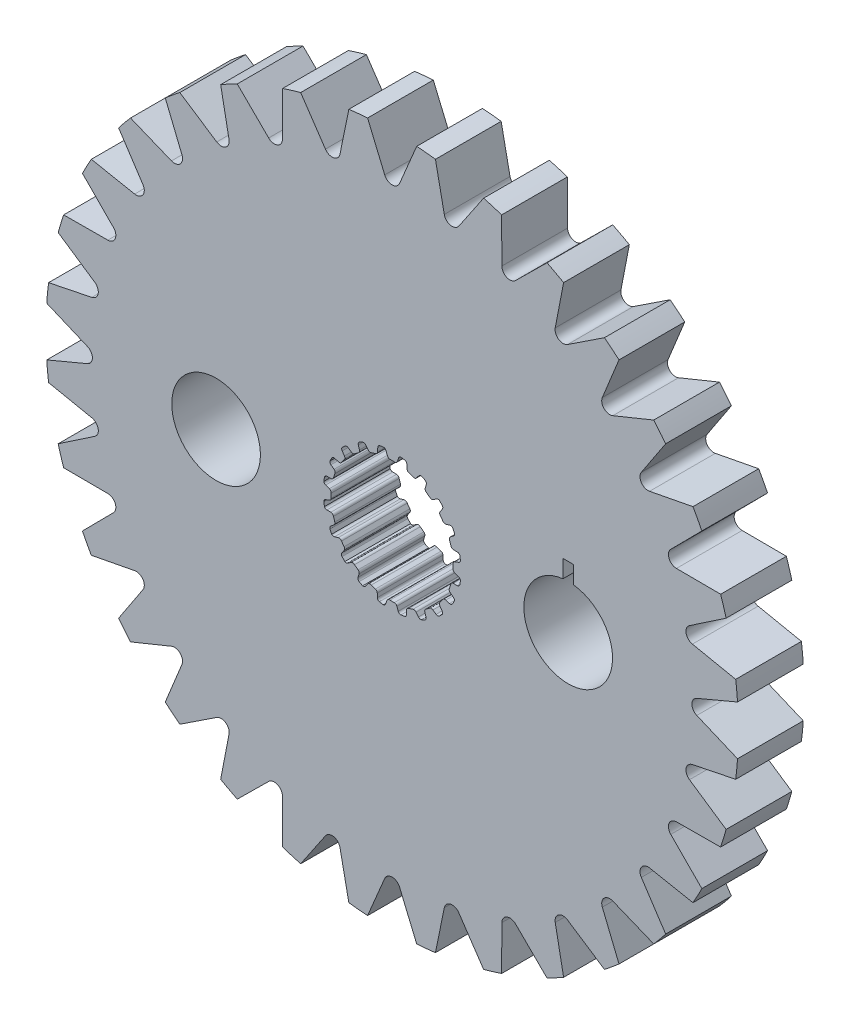
from build123d import *

# Parameters (mm, degrees)
SKETCH1_R           = 16.860601328
BOSS_EXTRUDE1_DEPTH = 1.6002
CUT_EXTRUDE1_DEPTH  = 3.2004
SKETCH4_R           = 2.159
CUT_EXTRUDE2_DEPTH  = 3.2004
SKETCH5_W           = 0.508
SKETCH5_H           = 1.27
CUT_EXTRUDE3_DEPTH  = 3.2004


with BuildPart() as part:
    # Sketch1 → Boss-Extrude1 (new body, symmetric)
    with BuildSketch(Plane.XY):
        Circle(SKETCH1_R)
        with BuildLine():
            Line((-0.106949245, 2.969874934), (0.106949245, 2.969874934))
            ThreePointArc((0.106949245, 2.969874934), (0.196343213, 2.986924176), (0.253739238, 3.057547504))
            Line((0.253739238, 3.057547504), (0.315888147, 3.237526941))
            ThreePointArc((0.315888147, 3.237526941), (0.359032156, 3.298322911), (0.4281449, 3.326269005))
            Line((0.4281449, 3.326269005), (0.620027588, 3.2937547))
            ThreePointArc((0.620027588, 3.2937547), (0.689621142, 3.24802576), (0.718272212, 3.169836791))
            Line((0.718272212, 3.169836791), (0.724389167, 2.979527391))
            ThreePointArc((0.724389167, 2.979527391), (0.750934762, 2.9040661), (0.816027049, 2.857568043))
            Line((0.816027049, 2.857568043), (1.019456602, 2.791469774))
            ThreePointArc((1.019456602, 2.791469774), (1.109743823, 2.780060312), (1.186154496, 2.829490741))
            Line((1.186154496, 2.829490741), (1.300878326, 2.981456288))
            ThreePointArc((1.300878326, 2.981456288), (1.360697704, 3.02594446), (1.435063648, 3.031165762))
            Line((1.435063648, 3.031165762), (1.607507455, 2.940947809))
            ThreePointArc((1.607507455, 2.940947809), (1.659563839, 2.875951412), (1.662650905, 2.792735615))
            Line((1.662650905, 2.792735615), (1.609659636, 2.609850378))
            ThreePointArc((1.609659636, 2.609850378), (1.611587176, 2.529879385), (1.659124931, 2.465542482))
            Line((1.659124931, 2.465542482), (1.832172444, 2.339816104))
            ThreePointArc((1.832172444, 2.339816104), (1.914514976, 2.301064775), (2.002460687, 2.32446371))
            Line((2.002460687, 2.32446371), (2.158529469, 2.433539921))
            ThreePointArc((2.158529469, 2.433539921), (2.229168681, 2.457365482), (2.301508367, 2.439350895))
            Line((2.301508367, 2.439350895), (2.437633293, 2.300260456))
            ThreePointArc((2.437633293, 2.300260456), (2.467056864, 2.222358901), (2.444277744, 2.14226202))
            Line((2.444277744, 2.14226202), (2.337365406, 1.984703026))
            ThreePointArc((2.337365406, 1.984703026), (2.314486209, 1.908050449), (2.339816104, 1.832172444))
            Line((2.339816104, 1.832172444), (2.465542482, 1.659124931))
            ThreePointArc((2.465542482, 1.659124931), (2.531880064, 1.596824985), (2.622752074, 1.591901975))
            Line((2.622752074, 1.591901975), (2.804888709, 1.64741171))
            ThreePointArc((2.804888709, 1.64741171), (2.879433095, 1.648242449), (2.942665411, 1.608755366))
            Line((2.942665411, 1.608755366), (3.0291466, 1.434407582))
            ThreePointArc((3.0291466, 1.434407582), (3.033057175, 1.351226417), (2.986641646, 1.282088892))
            Line((2.986641646, 1.282088892), (2.836273564, 1.165279113))
            ThreePointArc((2.836273564, 1.165279113), (2.790827206, 1.099448241), (2.791469774, 1.019456602))
            Line((2.791469774, 1.019456602), (2.857568043, 0.816027049))
            ThreePointArc((2.857568043, 0.816027049), (2.901407091, 0.736276839), (2.986310214, 0.703513784))
            Line((2.986310214, 0.703513784), (3.1766859, 0.700023363))
            ThreePointArc((3.1766859, 0.700023363), (3.247838536, 0.677777961), (3.295773863, 0.620683653))
            Line((3.295773863, 0.620683653), (3.324145932, 0.4281449))
            ThreePointArc((3.324145932, 0.4281449), (3.302160717, 0.347826477), (3.236652255, 0.29641597))
            Line((3.236652255, 0.29641597), (3.057547504, 0.231789562))
            ThreePointArc((3.057547504, 0.231789562), (2.993982591, 0.183224379), (2.969874934, 0.106949245))
            Line((2.969874934, 0.106949245), (2.969874934, -0.106949245))
            ThreePointArc((2.969874934, -0.106949245), (2.986924176, -0.196343213), (3.057547504, -0.253739238))
            Line((3.057547504, -0.253739238), (3.237526941, -0.315888147))
            ThreePointArc((3.237526941, -0.315888147), (3.298322911, -0.359032156), (3.326269005, -0.4281449))
            Line((3.326269005, -0.4281449), (3.2937547, -0.620027588))
            ThreePointArc((3.2937547, -0.620027588), (3.24802576, -0.689621142), (3.169836791, -0.718272212))
            Line((3.169836791, -0.718272212), (2.979527391, -0.724389167))
            ThreePointArc((2.979527391, -0.724389167), (2.9040661, -0.750934762), (2.857568043, -0.816027049))
            Line((2.857568043, -0.816027049), (2.791469774, -1.019456602))
            ThreePointArc((2.791469774, -1.019456602), (2.780060312, -1.109743823), (2.829490741, -1.186154496))
            Line((2.829490741, -1.186154496), (2.981456288, -1.300878326))
            ThreePointArc((2.981456288, -1.300878326), (3.02594446, -1.360697704), (3.031165762, -1.435063648))
            Line((3.031165762, -1.435063648), (2.940947809, -1.607507455))
            ThreePointArc((2.940947809, -1.607507455), (2.875951412, -1.659563839), (2.792735615, -1.662650905))
            Line((2.792735615, -1.662650905), (2.609850378, -1.609659636))
            ThreePointArc((2.609850378, -1.609659636), (2.529879385, -1.611587176), (2.465542482, -1.659124931))
            Line((2.465542482, -1.659124931), (2.339816104, -1.832172444))
            ThreePointArc((2.339816104, -1.832172444), (2.301064775, -1.914514976), (2.32446371, -2.002460687))
            Line((2.32446371, -2.002460687), (2.433539921, -2.158529469))
            ThreePointArc((2.433539921, -2.158529469), (2.457365482, -2.229168681), (2.439350895, -2.301508367))
            Line((2.439350895, -2.301508367), (2.300260456, -2.437633293))
            ThreePointArc((2.300260456, -2.437633293), (2.222358901, -2.467056864), (2.14226202, -2.444277744))
            Line((2.14226202, -2.444277744), (1.984703026, -2.337365406))
            ThreePointArc((1.984703026, -2.337365406), (1.908050449, -2.314486209), (1.832172444, -2.339816104))
            Line((1.832172444, -2.339816104), (1.659124931, -2.465542482))
            ThreePointArc((1.659124931, -2.465542482), (1.596824985, -2.531880064), (1.591901975, -2.622752074))
            Line((1.591901975, -2.622752074), (1.64741171, -2.804888709))
            ThreePointArc((1.64741171, -2.804888709), (1.648242449, -2.879433095), (1.608755366, -2.942665411))
            Line((1.608755366, -2.942665411), (1.434407582, -3.0291466))
            ThreePointArc((1.434407582, -3.0291466), (1.351226417, -3.033057175), (1.282088892, -2.986641646))
            Line((1.282088892, -2.986641646), (1.165279113, -2.836273564))
            ThreePointArc((1.165279113, -2.836273564), (1.099448241, -2.790827206), (1.019456602, -2.791469774))
            Line((1.019456602, -2.791469774), (0.816027049, -2.857568043))
            ThreePointArc((0.816027049, -2.857568043), (0.736276839, -2.901407091), (0.703513784, -2.986310214))
            Line((0.703513784, -2.986310214), (0.700023363, -3.1766859))
            ThreePointArc((0.700023363, -3.1766859), (0.677777961, -3.247838536), (0.620683653, -3.295773863))
            Line((0.620683653, -3.295773863), (0.4281449, -3.324145932))
            ThreePointArc((0.4281449, -3.324145932), (0.347826477, -3.302160717), (0.29641597, -3.236652255))
            Line((0.29641597, -3.236652255), (0.231789562, -3.057547504))
            ThreePointArc((0.231789562, -3.057547504), (0.183224379, -2.993982591), (0.106949245, -2.969874934))
            Line((0.106949245, -2.969874934), (-0.106949245, -2.969874934))
            ThreePointArc((-0.106949245, -2.969874934), (-0.196343213, -2.986924176), (-0.253739238, -3.057547504))
            Line((-0.253739238, -3.057547504), (-0.315888147, -3.237526941))
            ThreePointArc((-0.315888147, -3.237526941), (-0.359032156, -3.298322911), (-0.4281449, -3.326269005))
            Line((-0.4281449, -3.326269005), (-0.620027588, -3.2937547))
            ThreePointArc((-0.620027588, -3.2937547), (-0.689621142, -3.24802576), (-0.718272212, -3.169836791))
            Line((-0.718272212, -3.169836791), (-0.724389167, -2.979527391))
            ThreePointArc((-0.724389167, -2.979527391), (-0.750934762, -2.9040661), (-0.816027049, -2.857568043))
            Line((-0.816027049, -2.857568043), (-1.019456602, -2.791469774))
            ThreePointArc((-1.019456602, -2.791469774), (-1.109743823, -2.780060312), (-1.186154496, -2.829490741))
            Line((-1.186154496, -2.829490741), (-1.300878326, -2.981456288))
            ThreePointArc((-1.300878326, -2.981456288), (-1.360697704, -3.02594446), (-1.435063648, -3.031165762))
            Line((-1.435063648, -3.031165762), (-1.607507455, -2.940947809))
            ThreePointArc((-1.607507455, -2.940947809), (-1.659563839, -2.875951412), (-1.662650905, -2.792735615))
            Line((-1.662650905, -2.792735615), (-1.609659636, -2.609850378))
            ThreePointArc((-1.609659636, -2.609850378), (-1.611587176, -2.529879385), (-1.659124931, -2.465542482))
            Line((-1.659124931, -2.465542482), (-1.832172444, -2.339816104))
            ThreePointArc((-1.832172444, -2.339816104), (-1.914514976, -2.301064775), (-2.002460687, -2.32446371))
            Line((-2.002460687, -2.32446371), (-2.158529469, -2.433539921))
            ThreePointArc((-2.158529469, -2.433539921), (-2.229168681, -2.457365482), (-2.301508367, -2.439350895))
            Line((-2.301508367, -2.439350895), (-2.437633293, -2.300260456))
            ThreePointArc((-2.437633293, -2.300260456), (-2.467056864, -2.222358901), (-2.444277744, -2.14226202))
            Line((-2.444277744, -2.14226202), (-2.337365406, -1.984703026))
            ThreePointArc((-2.337365406, -1.984703026), (-2.314486209, -1.908050449), (-2.339816104, -1.832172444))
            Line((-2.339816104, -1.832172444), (-2.465542482, -1.659124931))
            ThreePointArc((-2.465542482, -1.659124931), (-2.531880064, -1.596824985), (-2.622752074, -1.591901975))
            Line((-2.622752074, -1.591901975), (-2.804888709, -1.64741171))
            ThreePointArc((-2.804888709, -1.64741171), (-2.879433095, -1.648242449), (-2.942665411, -1.608755366))
            Line((-2.942665411, -1.608755366), (-3.0291466, -1.434407582))
            ThreePointArc((-3.0291466, -1.434407582), (-3.033057175, -1.351226417), (-2.986641646, -1.282088892))
            Line((-2.986641646, -1.282088892), (-2.836273564, -1.165279113))
            ThreePointArc((-2.836273564, -1.165279113), (-2.790827206, -1.099448241), (-2.791469774, -1.019456602))
            Line((-2.791469774, -1.019456602), (-2.857568043, -0.816027049))
            ThreePointArc((-2.857568043, -0.816027049), (-2.901407091, -0.736276839), (-2.986310214, -0.703513784))
            Line((-2.986310214, -0.703513784), (-3.1766859, -0.700023363))
            ThreePointArc((-3.1766859, -0.700023363), (-3.247838536, -0.677777961), (-3.295773863, -0.620683653))
            Line((-3.295773863, -0.620683653), (-3.324145932, -0.4281449))
            ThreePointArc((-3.324145932, -0.4281449), (-3.302160717, -0.347826477), (-3.236652255, -0.29641597))
            Line((-3.236652255, -0.29641597), (-3.057547504, -0.231789562))
            ThreePointArc((-3.057547504, -0.231789562), (-2.993982591, -0.183224379), (-2.969874934, -0.106949245))
            Line((-2.969874934, -0.106949245), (-2.969874934, 0.106949245))
            ThreePointArc((-2.969874934, 0.106949245), (-2.986924176, 0.196343213), (-3.057547504, 0.253739238))
            Line((-3.057547504, 0.253739238), (-3.237526941, 0.315888147))
            ThreePointArc((-3.237526941, 0.315888147), (-3.298322911, 0.359032156), (-3.326269005, 0.4281449))
            Line((-3.326269005, 0.4281449), (-3.2937547, 0.620027588))
            ThreePointArc((-3.2937547, 0.620027588), (-3.24802576, 0.689621142), (-3.169836791, 0.718272212))
            Line((-3.169836791, 0.718272212), (-2.979527391, 0.724389167))
            ThreePointArc((-2.979527391, 0.724389167), (-2.9040661, 0.750934762), (-2.857568043, 0.816027049))
            Line((-2.857568043, 0.816027049), (-2.791469774, 1.019456602))
            ThreePointArc((-2.791469774, 1.019456602), (-2.780060312, 1.109743823), (-2.829490741, 1.186154496))
            Line((-2.829490741, 1.186154496), (-2.981456288, 1.300878326))
            ThreePointArc((-2.981456288, 1.300878326), (-3.02594446, 1.360697704), (-3.031165762, 1.435063648))
            Line((-3.031165762, 1.435063648), (-2.940947809, 1.607507455))
            ThreePointArc((-2.940947809, 1.607507455), (-2.875951412, 1.659563839), (-2.792735615, 1.662650905))
            Line((-2.792735615, 1.662650905), (-2.609850378, 1.609659636))
            ThreePointArc((-2.609850378, 1.609659636), (-2.529879385, 1.611587176), (-2.465542482, 1.659124931))
            Line((-2.465542482, 1.659124931), (-2.339816104, 1.832172444))
            ThreePointArc((-2.339816104, 1.832172444), (-2.301064775, 1.914514976), (-2.32446371, 2.002460687))
            Line((-2.32446371, 2.002460687), (-2.433539921, 2.158529469))
            ThreePointArc((-2.433539921, 2.158529469), (-2.457365482, 2.229168681), (-2.439350895, 2.301508367))
            Line((-2.439350895, 2.301508367), (-2.300260456, 2.437633293))
            ThreePointArc((-2.300260456, 2.437633293), (-2.222358901, 2.467056864), (-2.14226202, 2.444277744))
            Line((-2.14226202, 2.444277744), (-1.984703026, 2.337365406))
            ThreePointArc((-1.984703026, 2.337365406), (-1.908050449, 2.314486209), (-1.832172444, 2.339816104))
            Line((-1.832172444, 2.339816104), (-1.659124931, 2.465542482))
            ThreePointArc((-1.659124931, 2.465542482), (-1.596824985, 2.531880064), (-1.591901975, 2.622752074))
            Line((-1.591901975, 2.622752074), (-1.64741171, 2.804888709))
            ThreePointArc((-1.64741171, 2.804888709), (-1.648242449, 2.879433095), (-1.608755366, 2.942665411))
            Line((-1.608755366, 2.942665411), (-1.434407582, 3.0291466))
            ThreePointArc((-1.434407582, 3.0291466), (-1.351226417, 3.033057175), (-1.282088892, 2.986641646))
            Line((-1.282088892, 2.986641646), (-1.165279113, 2.836273564))
            ThreePointArc((-1.165279113, 2.836273564), (-1.099448241, 2.790827206), (-1.019456602, 2.791469774))
            Line((-1.019456602, 2.791469774), (-0.816027049, 2.857568043))
            ThreePointArc((-0.816027049, 2.857568043), (-0.736276839, 2.901407091), (-0.703513784, 2.986310214))
            Line((-0.703513784, 2.986310214), (-0.700023363, 3.1766859))
            ThreePointArc((-0.700023363, 3.1766859), (-0.677777961, 3.247838536), (-0.620683653, 3.295773863))
            Line((-0.620683653, 3.295773863), (-0.4281449, 3.324145932))
            ThreePointArc((-0.4281449, 3.324145932), (-0.347826477, 3.302160717), (-0.29641597, 3.236652255))
            Line((-0.29641597, 3.236652255), (-0.231789562, 3.057547504))
            ThreePointArc((-0.231789562, 3.057547504), (-0.183224379, 2.993982591), (-0.106949245, 2.969874934))
        make_face(mode=Mode.SUBTRACT)
    extrude(amount=BOSS_EXTRUDE1_DEPTH, both=True)

    # Sketch2 → Cut-Extrude1 (cut)
    with BuildSketch(Plane.XY.offset(1.6002)):
        with BuildLine():
            Line((-1.195753421, 16.818146476), (-0.361266579, 14.83454632))
            ThreePointArc((-0.361266579, 14.83454632), (0, 14.594594775), (0.361266579, 14.83454632))
            Line((0.361266579, 14.83454632), (1.195753421, 16.818146476))
            ThreePointArc((1.195753421, 16.818146476), (0, 16.860601328), (-1.195753421, 16.818146476))
        make_face()
        with BuildLine():
            Line((4.453834966, 16.261710587), (3.248401362, 14.479025059))
            ThreePointArc((3.248401362, 14.479025059), (2.847264194, 14.314163729), (2.539751475, 14.619984285))
            Line((2.539751475, 14.619984285), (2.108280258, 16.728270427))
            ThreePointArc((2.108280258, 16.728270427), (3.289340142, 16.536629601), (4.453834966, 16.261710587))
        make_face()
        with BuildLine():
            Line((7.540758131, 15.080346281), (6.010701902, 13.567082984))
            ThreePointArc((6.010701902, 13.567082984), (5.585109623, 13.483647398), (5.343168305, 13.843584454))
            Line((5.343168305, 13.843584454), (5.331293908, 15.995536327))
            ThreePointArc((5.331293908, 15.995536327), (6.452272788, 15.577164472), (7.540758131, 15.080346281))
        make_face()
        with BuildLine():
            Line((10.33789419, 13.319452723), (8.542014538, 12.133765519))
            ThreePointArc((8.542014538, 12.133765519), (8.10832242, 12.134962059), (7.941250173, 12.535183435))
            Line((7.941250173, 12.535183435), (8.349428924, 14.648102736))
            ThreePointArc((8.349428924, 14.648102736), (9.367248208, 14.019077649), (10.33789419, 13.319452723))
        make_face()
        with BuildLine():
            Line((12.737750772, 11.046700068), (10.745062347, 10.23415425))
            ThreePointArc((10.745062347, 10.23415425), (10.319936934, 10.319936934), (10.23415425, 10.745062347))
            Line((10.23415425, 10.745062347), (11.046700068, 12.737750772))
            ThreePointArc((11.046700068, 12.737750772), (11.922245534, 11.922245534), (12.737750772, 11.046700068))
        make_face()
        with BuildLine():
            Line((14.648102736, 8.349428924), (12.535183435, 7.941250173))
            ThreePointArc((12.535183435, 7.941250173), (12.134962059, 8.10832242), (12.133765519, 8.542014538))
            Line((12.133765519, 8.542014538), (13.319452723, 10.33789419))
            ThreePointArc((13.319452723, 10.33789419), (14.019077649, 9.367248208), (14.648102736, 8.349428924))
        make_face()
        with BuildLine():
            Line((15.995536327, 5.331293908), (13.843584454, 5.343168305))
            ThreePointArc((13.843584454, 5.343168305), (13.483647398, 5.585109623), (13.567082984, 6.010701902))
            Line((13.567082984, 6.010701902), (15.080346281, 7.540758131))
            ThreePointArc((15.080346281, 7.540758131), (15.577164472, 6.452272788), (15.995536327, 5.331293908))
        make_face()
        with BuildLine():
            Line((16.728270427, 2.108280258), (14.619984285, 2.539751475))
            ThreePointArc((14.619984285, 2.539751475), (14.314163729, 2.847264194), (14.479025059, 3.248401362))
            Line((14.479025059, 3.248401362), (16.261710587, 4.453834966))
            ThreePointArc((16.261710587, 4.453834966), (16.536629601, 3.289340142), (16.728270427, 2.108280258))
        make_face()
        with BuildLine():
            Line((16.818146476, -1.195753421), (14.83454632, -0.361266579))
            ThreePointArc((14.83454632, -0.361266579), (14.594594775, 0), (14.83454632, 0.361266579))
            Line((14.83454632, 0.361266579), (16.818146476, 1.195753421))
            ThreePointArc((16.818146476, 1.195753421), (16.860601328, 0), (16.818146476, -1.195753421))
        make_face()
        with BuildLine():
            Line((16.261710587, -4.453834966), (14.479025059, -3.248401362))
            ThreePointArc((14.479025059, -3.248401362), (14.314163729, -2.847264194), (14.619984285, -2.539751475))
            Line((14.619984285, -2.539751475), (16.728270427, -2.108280258))
            ThreePointArc((16.728270427, -2.108280258), (16.536629601, -3.289340142), (16.261710587, -4.453834966))
        make_face()
        with BuildLine():
            Line((15.080346281, -7.540758131), (13.567082984, -6.010701902))
            ThreePointArc((13.567082984, -6.010701902), (13.483647398, -5.585109623), (13.843584454, -5.343168305))
            Line((13.843584454, -5.343168305), (15.995536327, -5.331293908))
            ThreePointArc((15.995536327, -5.331293908), (15.577164472, -6.452272788), (15.080346281, -7.540758131))
        make_face()
        with BuildLine():
            Line((13.319452723, -10.33789419), (12.133765519, -8.542014538))
            ThreePointArc((12.133765519, -8.542014538), (12.134962059, -8.10832242), (12.535183435, -7.941250173))
            Line((12.535183435, -7.941250173), (14.648102736, -8.349428924))
            ThreePointArc((14.648102736, -8.349428924), (14.019077649, -9.367248208), (13.319452723, -10.33789419))
        make_face()
        with BuildLine():
            Line((11.046700068, -12.737750772), (10.23415425, -10.745062347))
            ThreePointArc((10.23415425, -10.745062347), (10.319936934, -10.319936934), (10.745062347, -10.23415425))
            Line((10.745062347, -10.23415425), (12.737750772, -11.046700068))
            ThreePointArc((12.737750772, -11.046700068), (11.922245534, -11.922245534), (11.046700068, -12.737750772))
        make_face()
        with BuildLine():
            Line((8.349428924, -14.648102736), (7.941250173, -12.535183435))
            ThreePointArc((7.941250173, -12.535183435), (8.10832242, -12.134962059), (8.542014538, -12.133765519))
            Line((8.542014538, -12.133765519), (10.33789419, -13.319452723))
            ThreePointArc((10.33789419, -13.319452723), (9.367248208, -14.019077649), (8.349428924, -14.648102736))
        make_face()
        with BuildLine():
            Line((5.331293908, -15.995536327), (5.343168305, -13.843584454))
            ThreePointArc((5.343168305, -13.843584454), (5.585109623, -13.483647398), (6.010701902, -13.567082984))
            Line((6.010701902, -13.567082984), (7.540758131, -15.080346281))
            ThreePointArc((7.540758131, -15.080346281), (6.452272788, -15.577164472), (5.331293908, -15.995536327))
        make_face()
        with BuildLine():
            Line((2.108280258, -16.728270427), (2.539751475, -14.619984285))
            ThreePointArc((2.539751475, -14.619984285), (2.847264194, -14.314163729), (3.248401362, -14.479025059))
            Line((3.248401362, -14.479025059), (4.453834966, -16.261710587))
            ThreePointArc((4.453834966, -16.261710587), (3.289340142, -16.536629601), (2.108280258, -16.728270427))
        make_face()
        with BuildLine():
            Line((-1.195753421, -16.818146476), (-0.361266579, -14.83454632))
            ThreePointArc((-0.361266579, -14.83454632), (0, -14.594594775), (0.361266579, -14.83454632))
            Line((0.361266579, -14.83454632), (1.195753421, -16.818146476))
            ThreePointArc((1.195753421, -16.818146476), (0, -16.860601328), (-1.195753421, -16.818146476))
        make_face()
        with BuildLine():
            Line((-4.453834966, -16.261710587), (-3.248401362, -14.479025059))
            ThreePointArc((-3.248401362, -14.479025059), (-2.847264194, -14.314163729), (-2.539751475, -14.619984285))
            Line((-2.539751475, -14.619984285), (-2.108280258, -16.728270427))
            ThreePointArc((-2.108280258, -16.728270427), (-3.289340142, -16.536629601), (-4.453834966, -16.261710587))
        make_face()
        with BuildLine():
            Line((-7.540758131, -15.080346281), (-6.010701902, -13.567082984))
            ThreePointArc((-6.010701902, -13.567082984), (-5.585109623, -13.483647398), (-5.343168305, -13.843584454))
            Line((-5.343168305, -13.843584454), (-5.331293908, -15.995536327))
            ThreePointArc((-5.331293908, -15.995536327), (-6.452272788, -15.577164472), (-7.540758131, -15.080346281))
        make_face()
        with BuildLine():
            Line((-10.33789419, -13.319452723), (-8.542014538, -12.133765519))
            ThreePointArc((-8.542014538, -12.133765519), (-8.10832242, -12.134962059), (-7.941250173, -12.535183435))
            Line((-7.941250173, -12.535183435), (-8.349428924, -14.648102736))
            ThreePointArc((-8.349428924, -14.648102736), (-9.367248208, -14.019077649), (-10.33789419, -13.319452723))
        make_face()
        with BuildLine():
            Line((-12.737750772, -11.046700068), (-10.745062347, -10.23415425))
            ThreePointArc((-10.745062347, -10.23415425), (-10.319936934, -10.319936934), (-10.23415425, -10.745062347))
            Line((-10.23415425, -10.745062347), (-11.046700068, -12.737750772))
            ThreePointArc((-11.046700068, -12.737750772), (-11.922245534, -11.922245534), (-12.737750772, -11.046700068))
        make_face()
        with BuildLine():
            Line((-14.648102736, -8.349428924), (-12.535183435, -7.941250173))
            ThreePointArc((-12.535183435, -7.941250173), (-12.134962059, -8.10832242), (-12.133765519, -8.542014538))
            Line((-12.133765519, -8.542014538), (-13.319452723, -10.33789419))
            ThreePointArc((-13.319452723, -10.33789419), (-14.019077649, -9.367248208), (-14.648102736, -8.349428924))
        make_face()
        with BuildLine():
            Line((-15.995536327, -5.331293908), (-13.843584454, -5.343168305))
            ThreePointArc((-13.843584454, -5.343168305), (-13.483647398, -5.585109623), (-13.567082984, -6.010701902))
            Line((-13.567082984, -6.010701902), (-15.080346281, -7.540758131))
            ThreePointArc((-15.080346281, -7.540758131), (-15.577164472, -6.452272788), (-15.995536327, -5.331293908))
        make_face()
        with BuildLine():
            Line((-16.728270427, -2.108280258), (-14.619984285, -2.539751475))
            ThreePointArc((-14.619984285, -2.539751475), (-14.314163729, -2.847264194), (-14.479025059, -3.248401362))
            Line((-14.479025059, -3.248401362), (-16.261710587, -4.453834966))
            ThreePointArc((-16.261710587, -4.453834966), (-16.536629601, -3.289340142), (-16.728270427, -2.108280258))
        make_face()
        with BuildLine():
            Line((-16.818146476, 1.195753421), (-14.83454632, 0.361266579))
            ThreePointArc((-14.83454632, 0.361266579), (-14.594594775, 0), (-14.83454632, -0.361266579))
            Line((-14.83454632, -0.361266579), (-16.818146476, -1.195753421))
            ThreePointArc((-16.818146476, -1.195753421), (-16.860601328, 0), (-16.818146476, 1.195753421))
        make_face()
        with BuildLine():
            Line((-16.261710587, 4.453834966), (-14.479025059, 3.248401362))
            ThreePointArc((-14.479025059, 3.248401362), (-14.314163729, 2.847264194), (-14.619984285, 2.539751475))
            Line((-14.619984285, 2.539751475), (-16.728270427, 2.108280258))
            ThreePointArc((-16.728270427, 2.108280258), (-16.536629601, 3.289340142), (-16.261710587, 4.453834966))
        make_face()
        with BuildLine():
            Line((-15.080346281, 7.540758131), (-13.567082984, 6.010701902))
            ThreePointArc((-13.567082984, 6.010701902), (-13.483647398, 5.585109623), (-13.843584454, 5.343168305))
            Line((-13.843584454, 5.343168305), (-15.995536327, 5.331293908))
            ThreePointArc((-15.995536327, 5.331293908), (-15.577164472, 6.452272788), (-15.080346281, 7.540758131))
        make_face()
        with BuildLine():
            Line((-13.319452723, 10.33789419), (-12.133765519, 8.542014538))
            ThreePointArc((-12.133765519, 8.542014538), (-12.134962059, 8.10832242), (-12.535183435, 7.941250173))
            Line((-12.535183435, 7.941250173), (-14.648102736, 8.349428924))
            ThreePointArc((-14.648102736, 8.349428924), (-14.019077649, 9.367248208), (-13.319452723, 10.33789419))
        make_face()
        with BuildLine():
            Line((-11.046700068, 12.737750772), (-10.23415425, 10.745062347))
            ThreePointArc((-10.23415425, 10.745062347), (-10.319936934, 10.319936934), (-10.745062347, 10.23415425))
            Line((-10.745062347, 10.23415425), (-12.737750772, 11.046700068))
            ThreePointArc((-12.737750772, 11.046700068), (-11.922245534, 11.922245534), (-11.046700068, 12.737750772))
        make_face()
        with BuildLine():
            Line((-8.349428924, 14.648102736), (-7.941250173, 12.535183435))
            ThreePointArc((-7.941250173, 12.535183435), (-8.10832242, 12.134962059), (-8.542014538, 12.133765519))
            Line((-8.542014538, 12.133765519), (-10.33789419, 13.319452723))
            ThreePointArc((-10.33789419, 13.319452723), (-9.367248208, 14.019077649), (-8.349428924, 14.648102736))
        make_face()
        with BuildLine():
            Line((-5.331293908, 15.995536327), (-5.343168305, 13.843584454))
            ThreePointArc((-5.343168305, 13.843584454), (-5.585109623, 13.483647398), (-6.010701902, 13.567082984))
            Line((-6.010701902, 13.567082984), (-7.540758131, 15.080346281))
            ThreePointArc((-7.540758131, 15.080346281), (-6.452272788, 15.577164472), (-5.331293908, 15.995536327))
        make_face()
        with BuildLine():
            Line((-2.108280258, 16.728270427), (-2.539751475, 14.619984285))
            ThreePointArc((-2.539751475, 14.619984285), (-2.847264194, 14.314163729), (-3.248401362, 14.479025059))
            Line((-3.248401362, 14.479025059), (-4.453834966, 16.261710587))
            ThreePointArc((-4.453834966, 16.261710587), (-3.289340142, 16.536629601), (-2.108280258, 16.728270427))
        make_face()
    extrude(amount=-CUT_EXTRUDE1_DEPTH, mode=Mode.SUBTRACT)

    # Sketch4 → Cut-Extrude2 (cut)
    with BuildSketch(Plane.XY.offset(1.6002)):
        with Locations((8.5725, 0)):
            Circle(SKETCH4_R)
        with Locations((-8.5725, 0)):
            Circle(SKETCH4_R)
    extrude(amount=-CUT_EXTRUDE2_DEPTH, mode=Mode.SUBTRACT)

    # Sketch5 → Cut-Extrude3 (cut)
    with BuildSketch(Plane.XY.offset(1.6002)):
        with Locations((8.5725, 2.36728)):
            Rectangle(SKETCH5_W, SKETCH5_H)
    extrude(amount=-CUT_EXTRUDE3_DEPTH, mode=Mode.SUBTRACT)


solid = part.part
